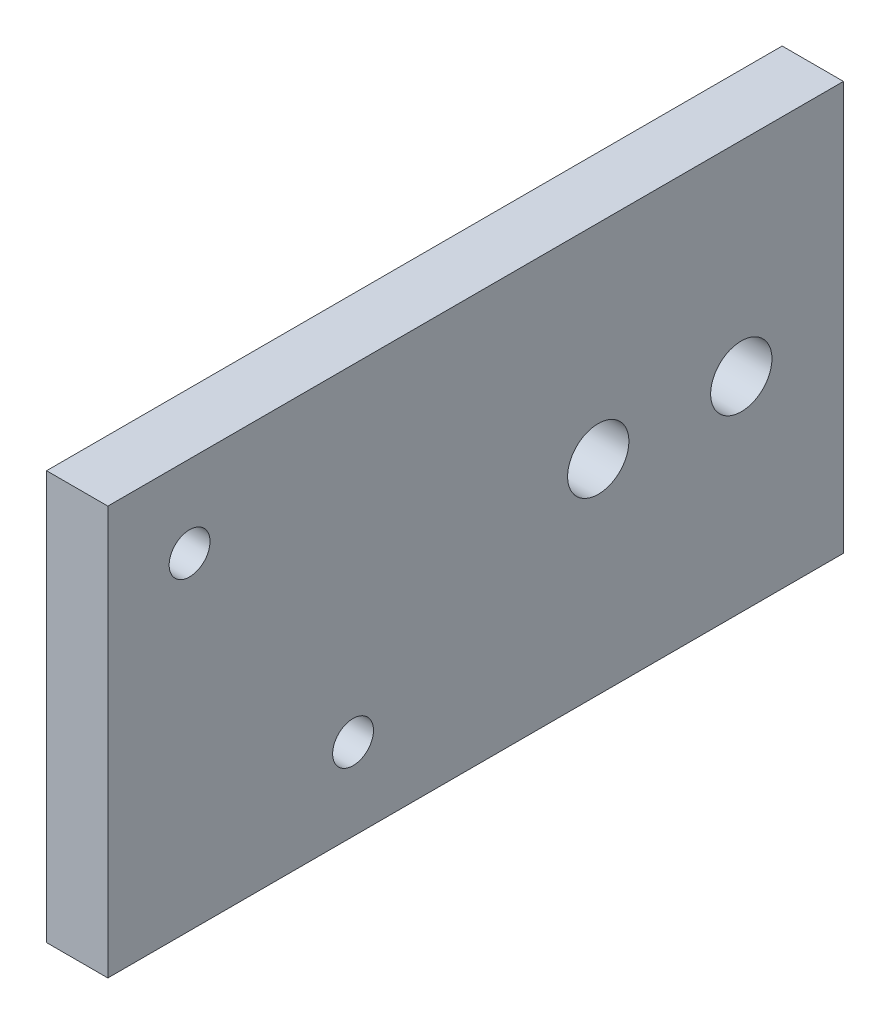
from build123d import *

# Parameters (mm, degrees)
CROQUIS1_W              = 15
CROQUIS1_H              = 20
CROQUIS1_R              = 1.5
SALIENTE_EXTRUIR1_DEPTH = 3
CROQUIS2_R              = 1
CORTAR_EXTRUIR1_DEPTH   = 10


with BuildPart() as part:
    # Croquis1 → Saliente-Extruir1 (new body)
    with BuildSketch(Plane(origin=(0, 0, 0), x_dir=(0, 0, -1), z_dir=(1, 0, 0))):
        with Locations((-10.5, 0)):
            Rectangle(CROQUIS1_W, CROQUIS1_H)
        Polygon((0, 0), (0, -10), (18, -10), (18, 10), (0, 10), align=None)
        with Locations((6, 0)):
            Circle(CROQUIS1_R, mode=Mode.SUBTRACT)
        with Locations((13, 0)):
            Circle(CROQUIS1_R, mode=Mode.SUBTRACT)
        Polygon((-3, 10), (-3, -10), (0, -10), (0, 0), (0, 10), align=None)
    extrude(amount=SALIENTE_EXTRUIR1_DEPTH)

    # Croquis2 → Cortar-Extruir1 (cut)
    with BuildSketch(Plane(origin=(3, 0, 0), x_dir=(0, 0, -1), z_dir=(1, 0, 0))):
        with Locations((-14, 6)):
            Circle(CROQUIS2_R)
        with Locations((-6, -6)):
            Circle(CROQUIS2_R)
    extrude(amount=-CORTAR_EXTRUIR1_DEPTH, mode=Mode.SUBTRACT)


solid = part.part
